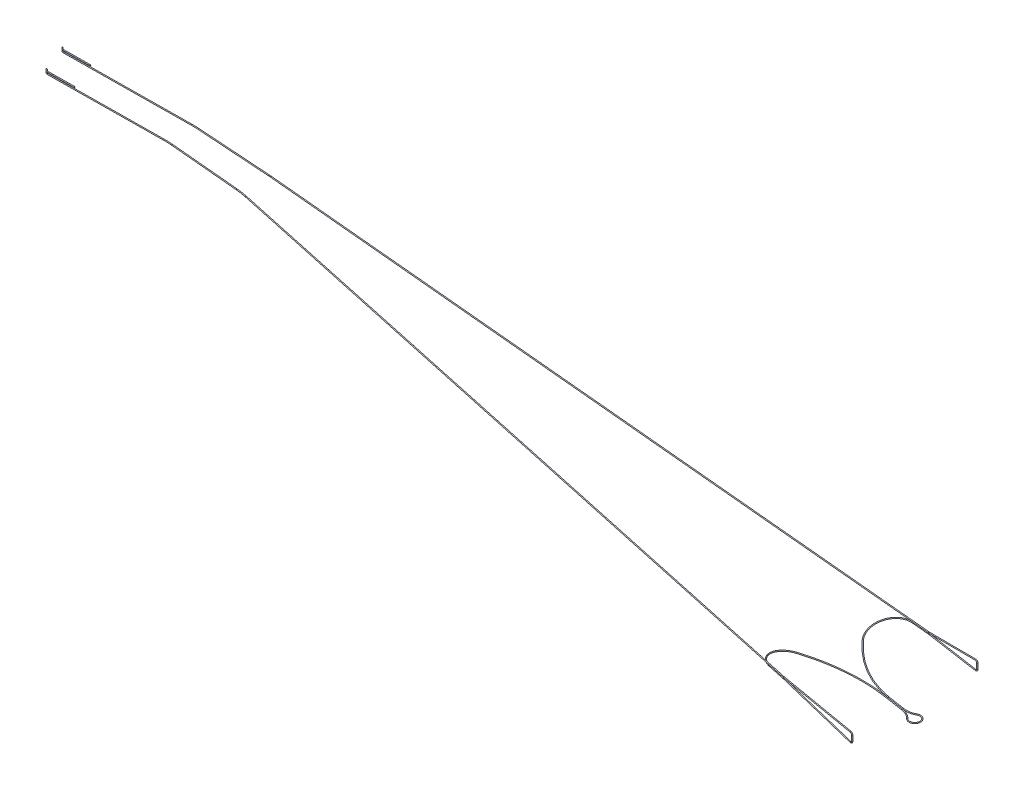
from build123d import *

# Parameters (mm, degrees)
SKETCH10_R = 0.25
SKETCH13_R = 0.25
SKETCH14_R = 0.25
SKETCH11_R = 0.25
SKETCH15_R = 0.25
SKETCH16_R = 0.25
SKETCH12_R = 0.246722014
SKETCH25_R = 0.25
SKETCH26_R = 0.25
SKETCH27_R = 0.25
SKETCH28_R = 0.25
SKETCH29_R = 0.25
SKETCH30_R = 0.25


with BuildPart() as part:
    # Sweep1: sweep along a path in Sketch2
    with BuildLine(Plane(origin=(0, 0, 0), x_dir=(1, 0, 0), z_dir=(0, 1, 0))) as sweep1_path:
        Line((-553.016712609, 76.739409244), (-481.925457981, 77.479943146))
        ThreePointArc((-481.925457981, 77.479943146), (-480.001040475, 77.462950438), (-478.078702376, 77.371913492))
        Line((-478.078702376, 77.371913492), (-435.598402593, 74.539893506))
        ThreePointArc((-435.598402593, 74.539893506), (-435.00028227, 74.496414451), (-434.402726445, 74.445764815))
        Line((-434.402726445, 74.445764815), (-29.877077521, 37.712976005))
    # Sketch10 → Sweep1 (sweep)
    with BuildSketch(Plane(origin=(-553.016712609, 0, -76.739409244), x_dir=(-0.010416102, 0, -0.999945751), z_dir=(0.999945751, 0, -0.010416102))):
        Circle(SKETCH10_R)
    sweep(path=sweep1_path.line)

    # Sweep2: sweep along a path in Sketch5
    with BuildLine(Plane(origin=(3.152169783, 0, -34.713768491), x_dir=(-0.995902584, 0, -0.090432533), z_dir=(0.090432533, 0, -0.995902584))) as sweep2_path:
        Line((43.165138672, -0.6), (33.165138672, -0.6))
        ThreePointArc((33.165138672, -0.6), (33.000489736, -0.602711663), (32.836019389, -0.610843709))
        Line((32.836019389, -0.610843709), (4.230962529, -2.497831258))
        ThreePointArc((4.230962529, -2.497831258), (3.481700254, -2.23000817), (3.165138672, -1.5))
        Line((3.165138672, -1.5), (3.165138672, 1.5))
        ThreePointArc((3.165138672, 1.5), (3.489365392, 2.23710954), (4.25179962, 2.496237863))
        Line((4.25179962, 2.496237863), (32.731833935, 0.018810684))
        ThreePointArc((32.731833935, 0.018810684), (32.948282247, 0.004704885), (33.165138672, 0))
    # Sketch13 → Sweep2 (sweep)
    with BuildSketch(Plane(origin=(-33.029247304, 0, -2.999207514), x_dir=(0.090432533, 0, -0.995902584), z_dir=(0.995902584, 0, 0.090432533))):
        with Locations((34.856590441, 0)):
            Circle(SKETCH13_R)
    sweep(path=sweep2_path.line)

    # Sweep3: sweep along a path in Sketch8
    with BuildLine(Plane(origin=(0.158416022, -7.921134589, -1.744581505), x_dir=(0.999809183, 0.018956258, 0.00471788), z_dir=(0.019527343, -0.976408245, -0.215047951))) as sweep3_path:
        ThreePointArc((-40.022067478, -37.563175786), (-51.114443307, -31.46117381), (-49.6770536, -18.883052309))
        ThreePointArc((-49.6770536, -18.883052309), (-35.365036785, -7.153824973), (-17.842776045, -1.205801955))
    # Sketch14 → Sweep3 (sweep)
    with BuildSketch(Plane(origin=(-42.988273144, 0, -3.903532849), x_dir=(-0.090432533, 0, 0.995902584), z_dir=(-0.995902584, 0, -0.090432533))):
        with Locations((-34.856590441, -0.6)):
            Circle(SKETCH14_R)
    sweep(path=sweep3_path.line)



with BuildPart() as body_2:
    # Sweep4: sweep along a path in Sketch3
    with BuildLine(Plane(origin=(0, 0, 0), x_dir=(1, 0, 0), z_dir=(0, 1, 0))) as sweep4_path:
        Line((-48.883532963, -24.492849811), (-431.988263522, 57.852649746))
        ThreePointArc((-431.988263522, 57.852649746), (-435.014185353, 58.406260938), (-438.068424196, 58.772748817))
        Line((-438.068424196, 58.772748817), (-477.530903099, 62.28052472))
        ThreePointArc((-477.530903099, 62.28052472), (-480.002401671, 62.438638603), (-482.478697692, 62.474180232))
        Line((-482.478697692, 62.474180232), (-546.985457353, 61.802234819))
    # Sketch11 → Sweep4 (sweep)
    with BuildSketch(Plane(origin=(-546.985457353, 0, -61.802234819), x_dir=(0.010416102, 0, 0.999945751), z_dir=(-0.999945751, 0, 0.010416102))):
        Circle(SKETCH11_R)
    sweep(path=sweep4_path.line)

    # Sweep5: sweep along a path in Sketch6
    with BuildLine(Plane(origin=(-7.190772716, 0, 33.454397129), x_dir=(-0.977669488, -0.001547779, -0.210142752), z_dir=(0.210143004, 0, -0.977670659))) as sweep5_path:
        Line((52.571628789, -0.533994989), (42.644943787, -0.533994989))
        ThreePointArc((42.644943787, -0.533994989), (42.54425873, -0.53500884), (42.443614505, -0.538049981))
        Line((42.443614505, -0.538049981), (-6.322357175, -2.503247367))
        ThreePointArc((-6.322357175, -2.503247367), (-7.049973497, -2.227298843), (-7.354996322, -1.51138392))
        Line((-7.354996322, -1.51138392), (-7.354996322, 1.48861608))
        ThreePointArc((-7.354996322, 1.48861608), (-7.046703056, 2.207658005), (-6.313316668, 2.480073925))
        Line((-6.313316668, 2.480073925), (42.398078122, 0.072102995))
        ThreePointArc((42.398078122, 0.072102995), (42.521473303, 0.06752974), (42.644943787, 0.066005011))
    # Sketch15 → Sweep5 (sweep)
    with BuildSketch(Plane(origin=(-41.692760247, 0, -8.961547317), x_dir=(0.210143004, 0, -0.977670659), z_dir=(0.977670659, 0, 0.210143004))):
        with Locations((-34.218473074, 0)):
            Circle(SKETCH15_R)
    sweep(path=sweep5_path.line)

    # Sweep6: sweep along a path in Sketch9
    with BuildLine(Plane(origin=(-0.363088556, -7.879572815, 1.747271479), x_dir=(-0.998974794, 0.042695608, -0.015048125), z_dir=(0.044941501, 0.975298794, -0.216269563))) as sweep6_path:
        ThreePointArc((58.164120643, 22.059642217), (65.857403576, 13.97059894), (60.925803163, 3.955683025))
        ThreePointArc((60.925803163, 3.955683025), (39.83508155, -3.565434669), (17.447517685, -3.992908311))
    # Sketch16 → Sweep6 (sweep)
    with BuildSketch(Plane(origin=(-51.39686936, 0, -11.047373069), x_dir=(-0.210143004, 0, 0.977670659), z_dir=(-0.977670659, 0, -0.210143004))):
        with Locations((34.218473074, -0.615363592)):
            Circle(SKETCH16_R)
    sweep(path=sweep6_path.line)


with BuildPart() as part_1:
    add(part.part)

    add(body_2.part)  # Sweep7 merges body 2
    # Sweep7: sweep along a path in Sketch7
    with BuildLine(Plane(origin=(0, -8, 0), x_dir=(-1, 0, 0), z_dir=(0, 1, 0))) as sweep7_path:
        Line((17.680316152, -3.006338232), (7.795158727, -1.495158994))
        ThreePointArc((7.795158727, -1.495158994), (4.529034681, -1.53551227), (1.450149113, -2.626226866))
        ThreePointArc((1.450149113, -2.626226866), (-2.965547227, 0.453353772), (2.168540474, 2.073024895))
        ThreePointArc((2.168540474, 2.073024895), (4.78093609, 0.112263865), (7.885829482, -0.902049548))
        Line((7.885829482, -0.902049548), (17.770986906, -2.413228787))
    # Sketch12 → Sweep7 (sweep)
    with BuildSketch(Plane(origin=(-17.770986906, -8, -2.413228787), x_dir=(-0.151117924, 0, 0.988515742), z_dir=(-0.988515742, 0, -0.151117924))):
        Circle(SKETCH12_R)
    sweep(path=sweep7_path.line)

    # Sweep8: sweep along a path in Sketch17
    with BuildLine(Plane(origin=(0, 0, 0), x_dir=(1, 0, 0), z_dir=(0, 1, 0))) as sweep8_path:
        Line((-554.441265553, 77.724624402), (-553.726831836, 77.024921277))
        ThreePointArc((-553.726831836, 77.024921277), (-553.40016816, 76.811539512), (-553.016712609, 76.739409244))
    # Sketch25 → Sweep8 (sweep)
    with BuildSketch(Plane(origin=(-552.157430847, 0, 5.751639905), x_dir=(0.010416102, 0, 0.999945751), z_dir=(-0.999945751, 0, 0.010416102))):
        with Locations((-82.495524453, 0)):
            Circle(SKETCH25_R)
    sweep(path=sweep8_path.line)

    # Sweep9: sweep along a path in Sketch21
    with BuildLine(Plane(origin=(-232.591950079, 0, 237.488622712), x_dir=(-0.714433717, 0, -0.699703125), z_dir=(0.699703125, 0, -0.714433717))) as sweep9_path:
        ThreePointArc((450.495697014, 0), (450.995697014, 0.5), (450.495697014, 1))
    # Sketch26 → Sweep9 (sweep)
    with BuildSketch(Plane(origin=(-321.849315475, 0, -315.213247114), x_dir=(-0.699703125, 0, 0.714433717), z_dir=(-0.714433717, 0, -0.699703125))):
        with Locations((332.415193935, 0)):
            Circle(SKETCH26_R)
    sweep(path=sweep9_path.line)

    # Sweep10: sweep along a path in Sketch23
    with BuildLine(Plane(origin=(0, 1, 0), x_dir=(-1, 0, 0), z_dir=(0, 1, 0))) as sweep10_path:
        Line((538.016712609, -76.895659244), (553.016712609, -76.739409244))
        ThreePointArc((553.016712609, -76.739409244), (553.40016816, -76.811539512), (553.726831836, -77.024921277))
        Line((553.726831836, -77.024921277), (554.441265553, -77.724624402))
    # Sketch27 → Sweep10 (sweep)
    with BuildSketch(Plane(origin=(-321.849315475, 0, -315.213247114), x_dir=(0.699703125, 0, -0.714433717), z_dir=(0.714433717, 0, 0.699703125))):
        with Locations((-332.415193935, 1)):
            Circle(SKETCH27_R)
    sweep(path=sweep10_path.line)

    # Sweep11: sweep along a path in Sketch18
    with BuildLine(Plane(origin=(0, 0, 0), x_dir=(1, 0, 0), z_dir=(0, 1, 0))) as sweep11_path:
        Line((-548.410010298, 62.787449978), (-547.69557658, 62.087746853))
        ThreePointArc((-547.69557658, 62.087746853), (-547.368912904, 61.874365088), (-546.985457353, 61.802234819))
    # Sketch28 → Sweep11 (sweep)
    with BuildSketch(Plane(origin=(-546.282408639, 0, 5.690441757), x_dir=(0.010416102, 0, 0.999945751), z_dir=(-0.999945751, 0, 0.010416102))):
        with Locations((-67.496338189, 0)):
            Circle(SKETCH28_R)
    sweep(path=sweep11_path.line)

    # Sweep12: sweep along a path in Sketch22
    with BuildLine(Plane(origin=(-237.106107811, 0, 242.097815344), x_dir=(-0.714433717, 0, -0.699703125), z_dir=(0.699703125, 0, -0.714433717))) as sweep12_path:
        ThreePointArc((435.735177274, 0), (436.235177274, 0.5), (435.735177274, 1))
    # Sketch29 → Sweep12 (sweep)
    with BuildSketch(Plane(origin=(-311.303902487, 0, -304.885265322), x_dir=(-0.699703125, 0, 0.714433717), z_dir=(-0.714433717, 0, -0.699703125))):
        with Locations((338.866726835, 0)):
            Circle(SKETCH29_R)
    sweep(path=sweep12_path.line)

    # Sweep13: sweep along a path in Sketch24
    with BuildLine(Plane(origin=(0, 1, 0), x_dir=(-1, 0, 0), z_dir=(0, 1, 0))) as sweep13_path:
        Line((548.410010298, -62.787449978), (547.69557658, -62.087746853))
        ThreePointArc((547.69557658, -62.087746853), (547.368912904, -61.874365088), (546.985457353, -61.802234819))
        Line((546.985457353, -61.802234819), (531.985457353, -61.958484819))
    # Sketch30 → Sweep13 (sweep)
    with BuildSketch(Plane(origin=(-311.303902487, 0, -304.885265322), x_dir=(0.699703125, 0, -0.714433717), z_dir=(0.714433717, 0, 0.699703125))):
        with Locations((-338.866726835, 1)):
            Circle(SKETCH30_R)
    sweep(path=sweep13_path.line)


solid = part_1.part
